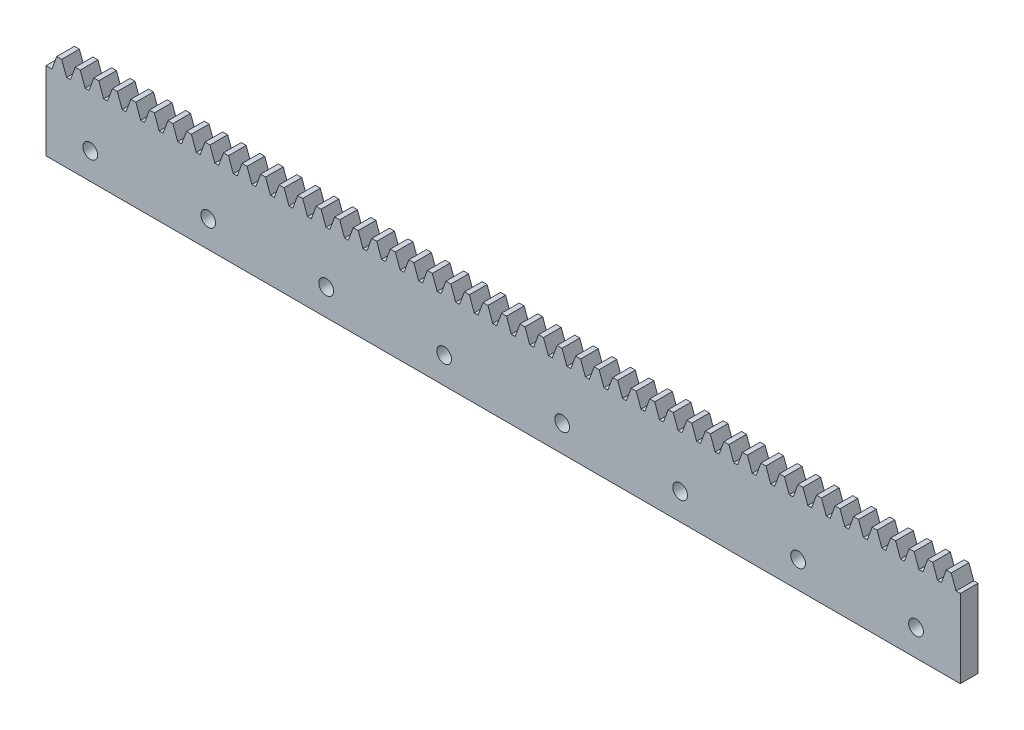
from build123d import *

# Parameters (mm, degrees)
SKETCH_1_W             = 155
SKETCH_1_H             = 9
EXTRUDE_1_DEPTH        = 3
SKETCH_3_W             = 155
SKETCH_3_H             = 3
EXTRUDE_2_DEPTH        = 4.25
EXTRUDE_3_DEPTH        = 3
M3X0_5_1_D             = 2.5
PATTERN_LINEAR_1_COUNT = 49
PATTERN_LINEAR_1_PITCH = 3.141592654
PATTERN_LINEAR_2_COUNT = 8
PATTERN_LINEAR_2_PITCH = 20


with BuildPart() as part:
    # 草圖1 → 填料-伸長1 (new body)
    with BuildSketch(Plane.XY):
        Rectangle(SKETCH_1_W, SKETCH_1_H)
    extrude(amount=EXTRUDE_1_DEPTH)

    # 草圖3 → 填料-伸長2 (add)
    with BuildSketch(Plane(origin=(0, 4.5, 0), x_dir=(1, 0, 0), z_dir=(0, 1, 0))):
        with Locations((0, -1.5)):
            Rectangle(SKETCH_3_W, SKETCH_3_H)
    extrude(amount=EXTRUDE_2_DEPTH)

    # 草圖4 → 填料-伸長3 (add, through all)
    with BuildSketch(Plane.XY):
        Polygon((-76.5, 8.75), (-74.019278088, 8.75), (-74.838211115, 11), (-75.681066973, 11), align=None)
    extrude_3 = extrude(amount=EXTRUDE_3_DEPTH)

    # M3x0.5 螺紋孔1 (through all)
    with Locations(Plane.XY.offset(3)):
        with Locations((-70, 0)):
            m3x0_5_1 = Hole(M3X0_5_1_D / 2)

    # 直線複製排列1: 填料-伸長3 ×49
    with Locations(*[(i * PATTERN_LINEAR_1_PITCH, 0, 0) for i in range(1, PATTERN_LINEAR_1_COUNT)]):
        add(extrude_3)

    # 直線複製排列2: M3x0.5 螺紋孔1 ×8
    with Locations(*[(i * PATTERN_LINEAR_2_PITCH, 0, 0) for i in range(1, PATTERN_LINEAR_2_COUNT)]):
        add(m3x0_5_1, mode=Mode.SUBTRACT)


solid = part.part
